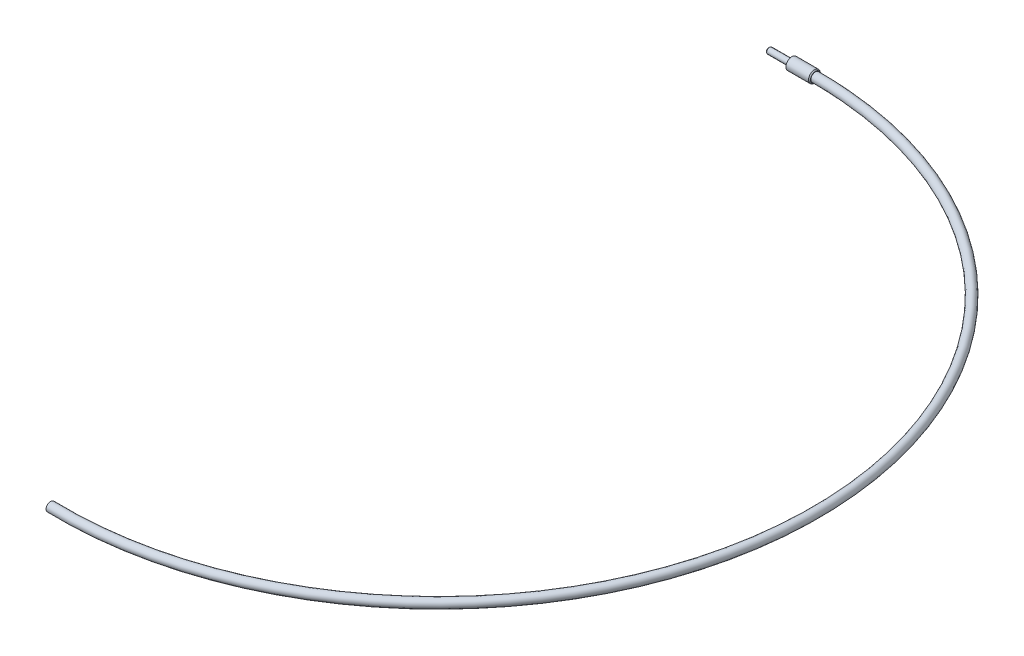
from build123d import *

# Parameters (mm, degrees)
SKETCH2_R           = 2.413
SKETCH3_R           = 3.175
BOSS_EXTRUDE1_DEPTH = 12.7
CHAMFER1_SIZE       = 0.508
SKETCH4_R           = 1.5875
BOSS_EXTRUDE2_DEPTH = 12.7
CHAMFER2_SIZE       = 0.7112


with BuildPart() as part:
    # Sweep1: sweep along a path in Sketch1
    with BuildLine(Plane(origin=(0, 0, 0), x_dir=(1, 0, 0), z_dir=(0, 1, 0))) as sweep1_path:
        ThreePointArc((-5.61287115, -203.122464729), (203.180615258, -2.806703327), (0, 203.2))
    # Sketch2 → Sweep1 (sweep)
    with BuildSketch(Plane(origin=(0, 0, 0), x_dir=(0, 0, -1), z_dir=(1, 0, 0))):
        with Locations((203.2, 0)):
            Circle(SKETCH2_R)
    sweep(path=sweep1_path.line)

    # Sketch3 → Boss-Extrude1 (add)
    with BuildSketch(Plane(origin=(0, 0, 0), x_dir=(0, 0, -1), z_dir=(1, 0, 0))):
        with Locations((203.2, 0)):
            Circle(SKETCH3_R)
    extrude(amount=-BOSS_EXTRUDE1_DEPTH)

    # Chamfer1
    chamfer1_edges = [part.edges().sort_by_distance(p)[0] for p in [
        (0, 0, -200.025),
    ]]
    chamfer(chamfer1_edges, length=CHAMFER1_SIZE)

    # Sketch4 → Boss-Extrude2 (add)
    with BuildSketch(Plane.ZY.offset(12.7)):
        with Locations((-203.2, 0)):
            Circle(SKETCH4_R)
    extrude(amount=BOSS_EXTRUDE2_DEPTH)

    # Chamfer2
    chamfer2_edges = [part.edges().sort_by_distance(p)[0] for p in [
        (-25.4, 0, -204.7875),
    ]]
    chamfer(chamfer2_edges, length=CHAMFER2_SIZE)


solid = part.part
